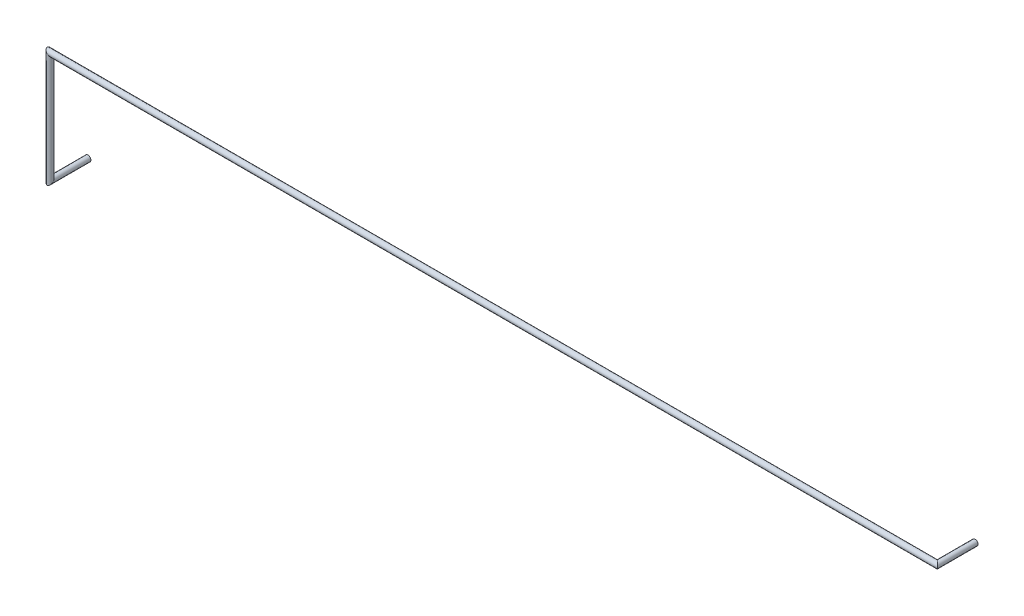
from build123d import *

# Parameters (mm, degrees)
SWEEP1_PROFILE_R = 0.2


with BuildPart() as part:
    # Sweep1: sweep along a curve in space
    with BuildLine() as sweep1_path:
        Line((0, 0, 0), (0, 0, 2.6))
        Line((0, 0, 2.6), (0, 7.62, 2.6))
        Line((0, 7.62, 2.6), (60.96, 7.62, 2.6))
        Line((60.96, 7.62, 2.6), (60.96, 7.62, 0))
    # Sweep1 profile (on start of the path) → Sweep1 (sweep)
    with BuildSketch(Plane.XY):
        Circle(SWEEP1_PROFILE_R)
    sweep(path=sweep1_path.line, transition=Transition.RIGHT)


solid = part.part
